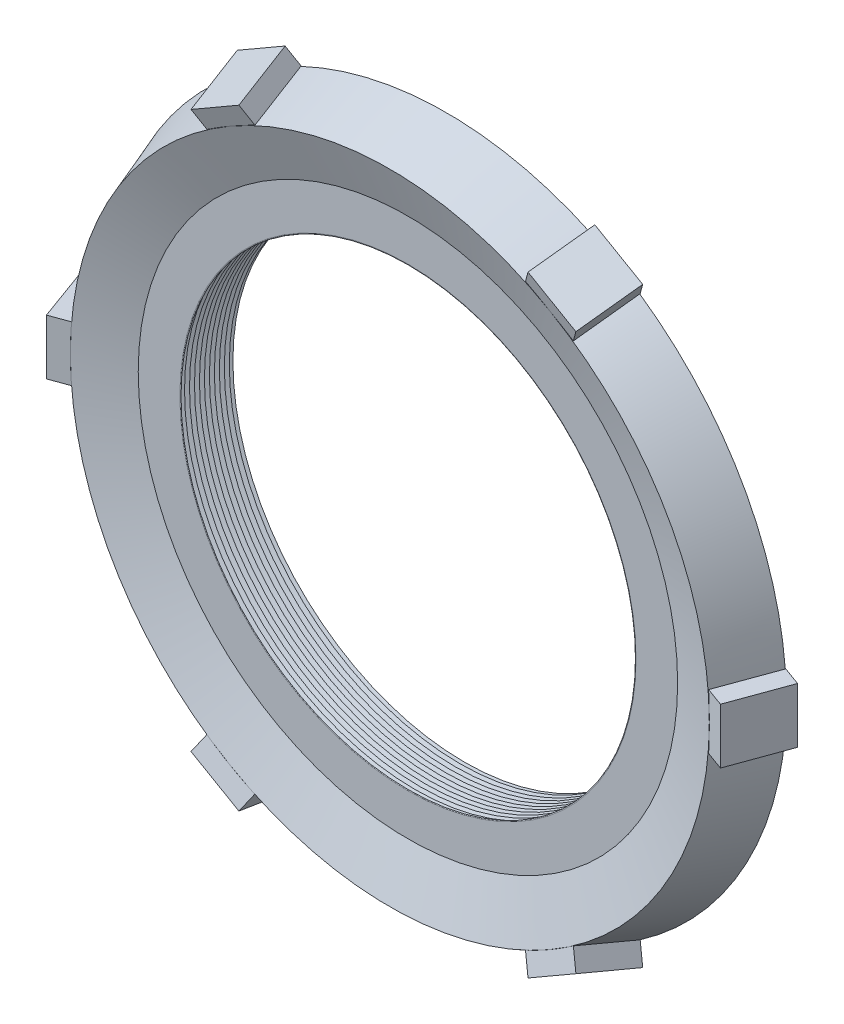
from build123d import *

# Parameters (mm, degrees)
EXTRUDE3_DEPTH    = 2.54
CIRPATTERN1_COUNT = 6
FILLET4_R         = 0.127
LPATTERN1_COUNT   = 11
LPATTERN1_PITCH   = 0.4572


with BuildPart() as part:
    # Sketch1 → Revolve1 (revolve)
    with BuildSketch(Plane(origin=(0, 0, 0), x_dir=(1, 0, 0), z_dir=(0, 1, 0)), mode=Mode.PRIVATE) as revolve1_sk:
        Polygon((20.828, 2.54), (26.67, 2.54), (31.242, 0.875928089), (29.351564777, -4.318), (24.779564777, -2.653928089), (20.828, -2.653928089), align=None)
    revolve(revolve1_sk.sketch.rotate(Axis((0, 0, -37.83814433), (0, 0, 1)), 180), axis=Axis((0, 0, -37.83814433), (0, 0, 1)))  # turned: the seam where the file's is

    # Sketch3 → Extrude3 (add, symmetric)
    with BuildSketch(Plane(origin=(0, 0, 0), x_dir=(1, 0, 0), z_dir=(0, 1, 0))):
        Polygon((30.226, 1.245721847), (32.851501182, 0.290117566), (30.961065959, -4.903810522), (28.335564777, -3.948206242), align=None)
    extrude3 = extrude(amount=EXTRUDE3_DEPTH, both=True)

    # CirPattern1: Extrude3 ×6 about axis
    cirpattern1_axis = Axis((0, 0, 0), (0, 0, 1))
    for i in range(1, CIRPATTERN1_COUNT):
        add(extrude3.rotate(cirpattern1_axis, i * 360 / CIRPATTERN1_COUNT))

    # Fillet4
    fillet4_edges = [part.edges().sort_by_distance(p)[0] for p in [
        (20.828, 0, 2.653928089),
        (20.828, 0, -2.54),
    ]]
    fillet(fillet4_edges, radius=FILLET4_R)

    # Sketch4 → Cut-Revolve1 (revolve, cut)
    with BuildSketch(Plane(origin=(0, 0, 0), x_dir=(1, 0, 0), z_dir=(0, 1, 0))):
        Polygon((-20.828, -2.653928089), (-20.828, -1.774046279), (-21.59, -2.213987184), align=None)
    cut_revolve1 = revolve(axis=Axis((0, 0, -37.83814433), (0, 0, 1)), mode=Mode.SUBTRACT)

    # LPattern1: Cut-Revolve1 ×11
    with Locations(*[(0, 0, -i * LPATTERN1_PITCH) for i in range(1, LPATTERN1_COUNT)]):
        add(cut_revolve1, mode=Mode.SUBTRACT)


solid = part.part
